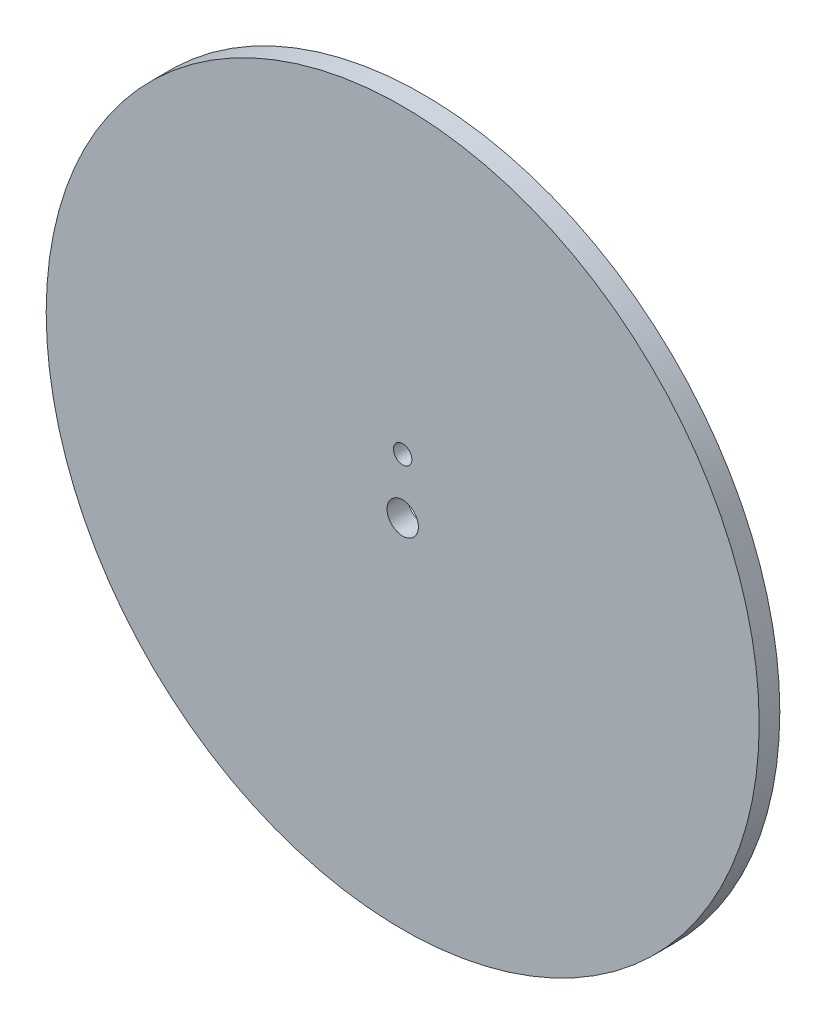
from build123d import *

# Parameters (mm, degrees)
SKETCH1_R           = 54.915
SKETCH1_R_2         = 2.415
SKETCH1_R_3         = 1.415
BOSS_EXTRUDE1_DEPTH = 3.175


with BuildPart() as part:
    # Sketch1 → Boss-Extrude1 (new body)
    with BuildSketch(Plane.XY):
        Circle(SKETCH1_R)
        Circle(SKETCH1_R_2, mode=Mode.SUBTRACT)
        with Locations((0, 8.5)):
            Circle(SKETCH1_R_3, mode=Mode.SUBTRACT)
    extrude(amount=BOSS_EXTRUDE1_DEPTH)


solid = part.part
